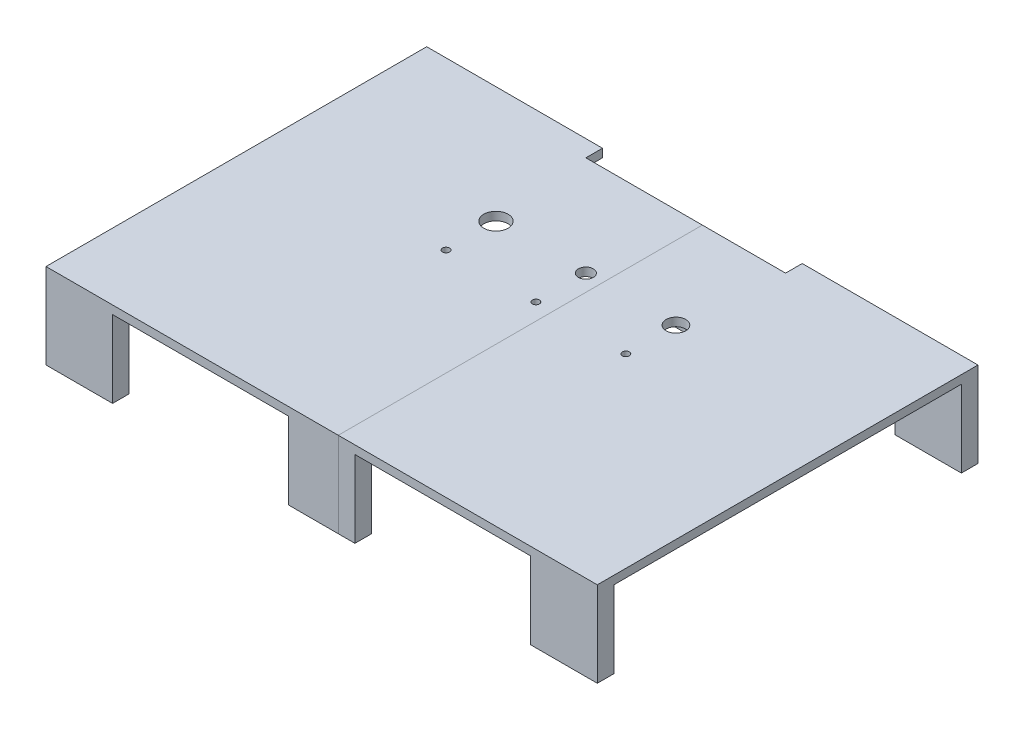
from build123d import *

# Parameters (mm, degrees)
SKETCH1_W                 = 420.6875
SKETCH1_H                 = 290.5125
DESKTOP_DEPTH             = 6.35
SKETCH5_W                 = 152.4
SKETCH5_H                 = 12.7
HDMI_SCREEN_CUTOUT_DEPTH  = 16.51
SKETCH8_R                 = 7.493
SKETCH8_R_2               = 9.271
SKETCH8_R_3               = 5.715
SKETCH8_R_4               = 2.667
SWITCHES_AND_LIGHTS_DEPTH = 16.51
SKETCH9_W                 = 50.8
SKETCH9_H                 = 12.7
BOSS_EXTRUDE1_DEPTH       = 58.7375


with BuildPart() as part:
    # Sketch1 → Desktop (new body)
    with BuildSketch(Plane(origin=(0, 0, 0), x_dir=(1, 0, 0), z_dir=(0, 1, 0))):
        Rectangle(SKETCH1_W, SKETCH1_H)
    extrude(amount=DESKTOP_DEPTH)

    # Sketch5 → HDMI Screen Cutout (cut)
    with BuildSketch(Plane(origin=(0, 6.35, 0), x_dir=(1, 0, 0), z_dir=(0, 1, 0))):
        with Locations((0, 138.90625)):
            Rectangle(SKETCH5_W, SKETCH5_H)
    extrude(amount=-HDMI_SCREEN_CUTOUT_DEPTH, mode=Mode.SUBTRACT)

    # Sketch8 → Switches and Lights (cut)
    with BuildSketch(Plane(origin=(0, 6.35, 0), x_dir=(1, 0, 0), z_dir=(0, 1, 0))):
        with Locations((68.73875, 56.35625)):
            Circle(SKETCH8_R)
        with Locations((-68.61175, 56.35625)):
            Circle(SKETCH8_R_2)
        with Locations((0, 56.35625)):
            Circle(SKETCH8_R_3)
        with Locations((-68.61175, 18.25625)):
            Circle(SKETCH8_R_4)
        with Locations((0, 18.25625)):
            Circle(SKETCH8_R_4)
        with Locations((68.61175, 18.25625)):
            Circle(SKETCH8_R_4)
    extrude(amount=-SWITCHES_AND_LIGHTS_DEPTH, mode=Mode.SUBTRACT)

    # Sketch9 → Boss-Extrude1 (add)
    with BuildSketch(Plane.XZ):
        with Locations((0, 138.90625)):
            Rectangle(SKETCH9_W, SKETCH9_H)
        with Locations((-184.94375, 138.90625)):
            Rectangle(SKETCH9_W, SKETCH9_H)
        with Locations((-184.94375, -138.90625)):
            Rectangle(SKETCH9_W, SKETCH9_H)
        with Locations((184.94375, -138.90625)):
            Rectangle(SKETCH9_W, SKETCH9_H)
        with Locations((184.94375, 138.90625)):
            Rectangle(SKETCH9_W, SKETCH9_H)
        with Locations((0, -126.20625)):
            Rectangle(SKETCH9_W, SKETCH9_H)
    extrude(amount=BOSS_EXTRUDE1_DEPTH)


with BuildPart() as body_2:
    # Split2: the piece on the far side of the plane
    add(part.part)
    split(bisect_by=Plane(origin=(12.7, 0, 0), x_dir=(0, 0, 1), z_dir=(1, 0, 0)), keep=Keep.BOTTOM)


with BuildPart() as part_1:
    add(part.part)

    # Split2
    split(bisect_by=Plane(origin=(12.7, 0, 0), x_dir=(0, 0, 1), z_dir=(1, 0, 0)), keep=Keep.TOP)


solid = Compound([body_2.part, part_1.part])
